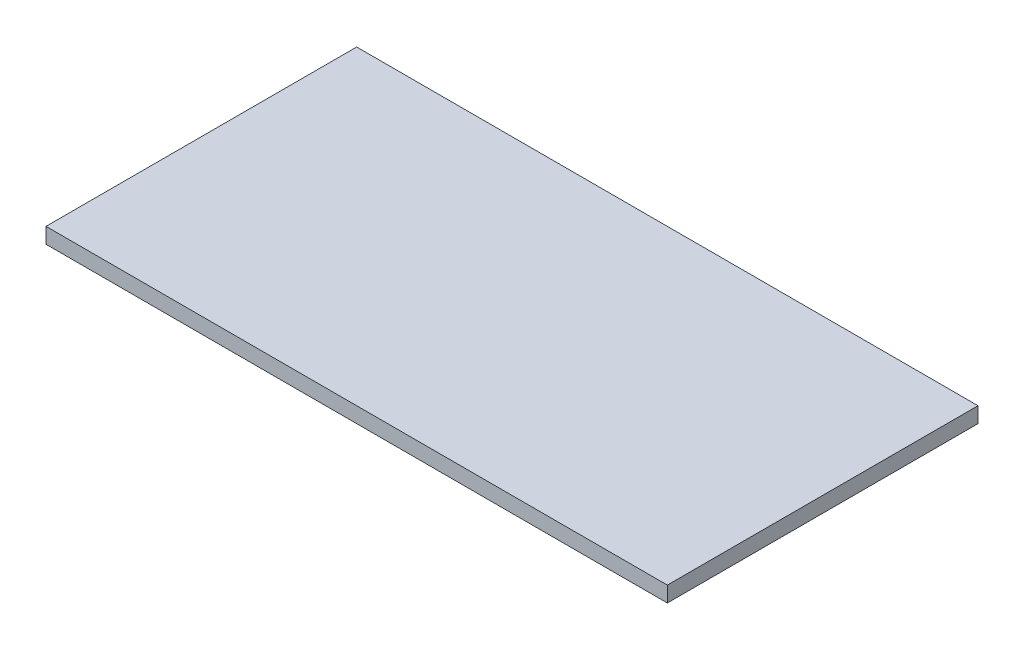
from build123d import *

# Parameters (mm, degrees)
SKETCH1_W           = 1200
SKETCH1_H           = 600
BOSS_EXTRUDE1_DEPTH = 30


with BuildPart() as part:
    # Sketch1 → Boss-Extrude1 (new body)
    with BuildSketch(Plane(origin=(0, 0, 0), x_dir=(1, 0, 0), z_dir=(0, 1, 0))):
        with Locations((-168.243243243, -17.22972973)):
            Rectangle(SKETCH1_W, SKETCH1_H)
    extrude(amount=BOSS_EXTRUDE1_DEPTH)


solid = part.part
